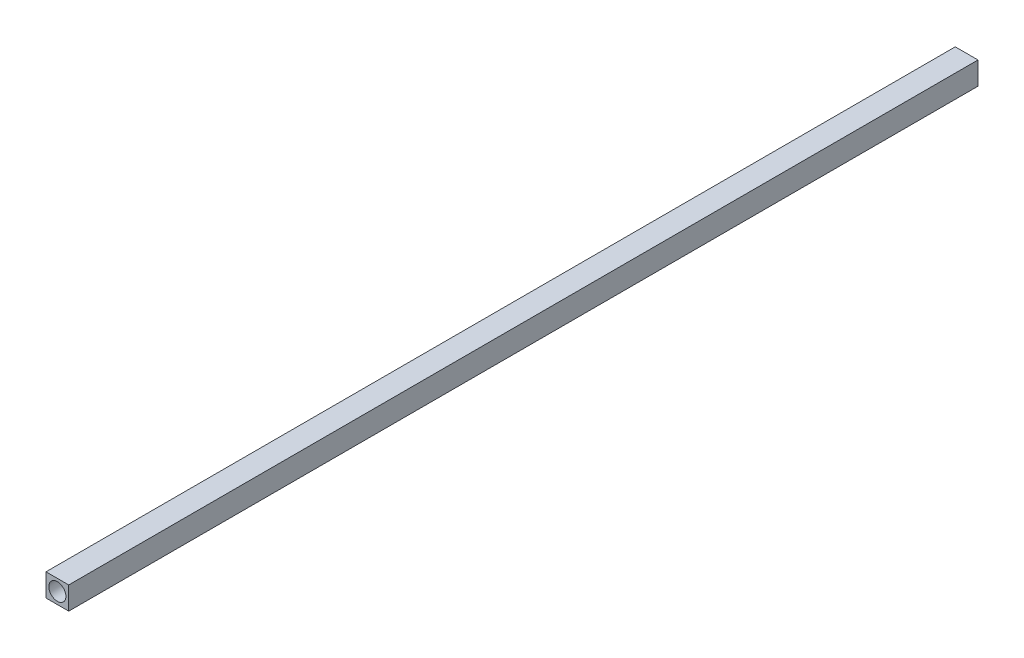
from build123d import *

# Parameters (mm, degrees)
SKETCH1_W           = 4
SKETCH1_H           = 4
SKETCH1_R           = 1.5
BOSS_EXTRUDE1_DEPTH = 160


with BuildPart() as part:
    # Sketch1 → Boss-Extrude1 (new body)
    with BuildSketch(Plane.XY):
        with Locations((2, 2)):
            Rectangle(SKETCH1_W, SKETCH1_H)
        with Locations((2, 2)):
            Circle(SKETCH1_R, mode=Mode.SUBTRACT)
    extrude(amount=BOSS_EXTRUDE1_DEPTH)


solid = part.part
